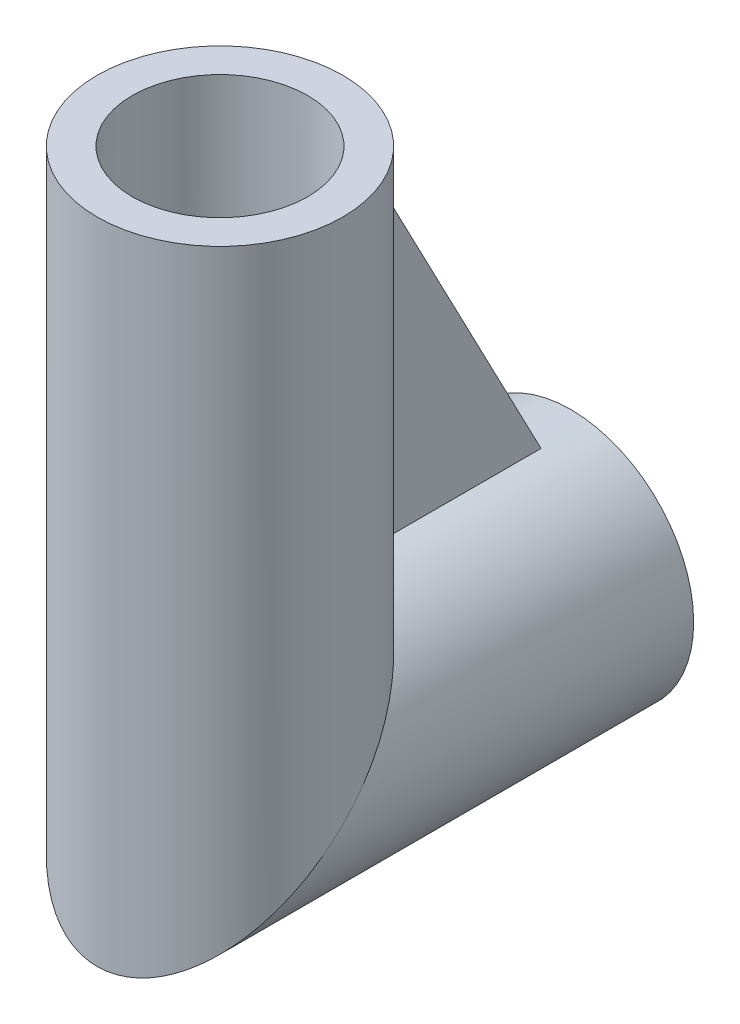
from build123d import *

# Parameters (mm, degrees)
SKETCH2_R           = 7
SKETCH2_R_2         = 5
BOSS_EXTRUDE1_DEPTH = 1


with BuildPart() as part:
    # Sweep1: sweep along a path in Sketch1
    with BuildLine(Plane.ZY) as sweep1_path:
        Line((0, 0), (20, 0))
        Line((20, 0), (20, 30))
    # Sketch2 → Sweep1 (sweep)
    with BuildSketch(Plane.XY):
        Circle(SKETCH2_R)
        Circle(SKETCH2_R_2, mode=Mode.SUBTRACT)
    sweep(path=sweep1_path.line, transition=Transition.RIGHT)

    # Sketch3 → Boss-Extrude1 (add, symmetric)
    with BuildSketch(Plane(origin=(0, 0, 0), x_dir=(0, 0, -1), z_dir=(1, 0, 0))):
        Polygon((-13.456771137, 6.543228863), (-2.5, 6.543228863), (-13.456771137, 27.5), align=None)
    extrude(amount=BOSS_EXTRUDE1_DEPTH, both=True)


solid = part.part
